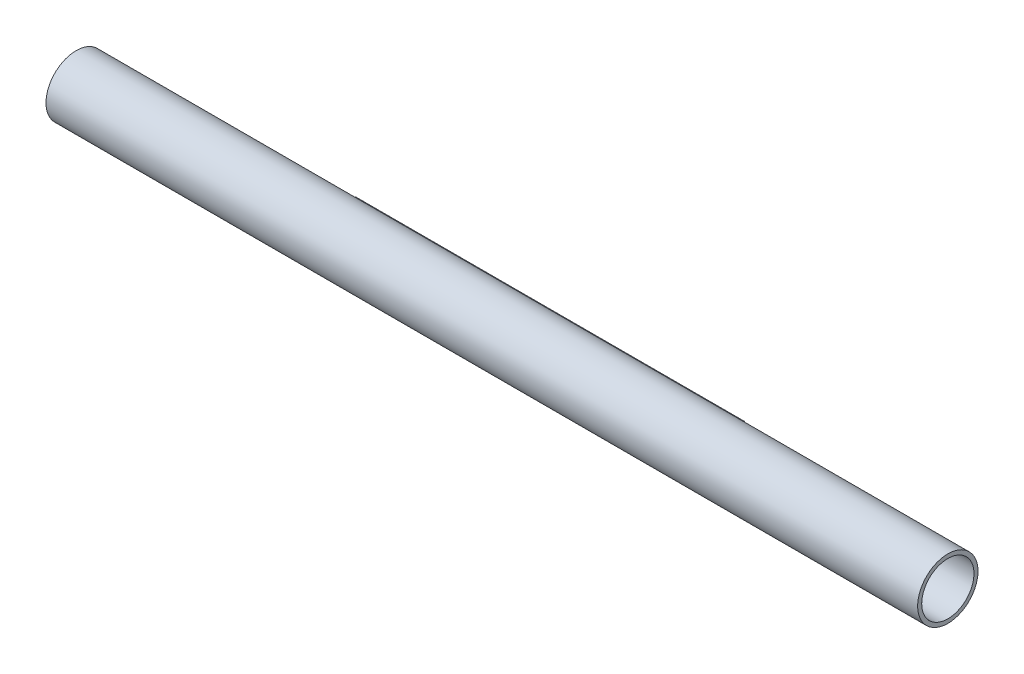
from build123d import *

# Parameters (mm, degrees)
BOSS_EXTRUDE1_DEPTH = 491.49
SKETCH2_R           = 38.1
BOSS_EXTRUDE2_DEPTH = 304.8
SKETCH3_R           = 38.1
BOSS_EXTRUDE3_DEPTH = 304.8
SKETCH4_R           = 33.02
CUT_EXTRUDE1_DEPTH  = 1102.09


with BuildPart() as part:
    # Sketch1 → Boss-Extrude1 (new body)
    with BuildSketch(Plane(origin=(0, 0, 0), x_dir=(0, 0, -1), z_dir=(1, 0, 0))):
        with BuildLine():
            Line((27.94, 6.35), (27.94, -6.35))
            Line((27.94, -6.35), (37.567106623, -6.35))
            ThreePointArc((37.567106623, -6.35), (37.966542918, -3.186160517), (38.1, 0))
            ThreePointArc((38.1, 0), (37.966542918, 3.186160517), (37.567106623, 6.35))
            Line((37.567106623, 6.35), (27.94, 6.35))
        make_face()
        with BuildLine():
            Line((37.567106623, -6.35), (27.94, -6.35))
            Line((27.94, -6.35), (27.94, 6.35))
            Line((27.94, 6.35), (37.567106623, 6.35))
            ThreePointArc((37.567106623, 6.35), (-38.1, 0), (37.567106623, -6.35))
        make_face()
        with BuildLine():
            ThreePointArc((38.1, 0), (37.966542918, -3.186160517), (37.567106623, -6.35))
            Line((37.567106623, -6.35), (48.26, -6.35))
            Line((48.26, -6.35), (48.26, 6.35))
            Line((48.26, 6.35), (37.567106623, 6.35))
            ThreePointArc((37.567106623, 6.35), (37.966542918, 3.186160517), (38.1, 0))
        make_face()
    extrude(amount=-BOSS_EXTRUDE1_DEPTH)

    # Sketch2 → Boss-Extrude2 (add)
    with BuildSketch(Plane(origin=(0, 0, 0), x_dir=(0, 0, -1), z_dir=(1, 0, 0))):
        Circle(SKETCH2_R)
    extrude(amount=BOSS_EXTRUDE2_DEPTH)

    # Sketch3 → Boss-Extrude3 (add)
    with BuildSketch(Plane.ZY.offset(491.49)):
        Circle(SKETCH3_R)
    extrude(amount=BOSS_EXTRUDE3_DEPTH)

    # Sketch4 → Cut-Extrude1 (cut, through all)
    with BuildSketch(Plane.ZY.offset(796.29)):
        Circle(SKETCH4_R)
    extrude(amount=-CUT_EXTRUDE1_DEPTH, mode=Mode.SUBTRACT)


solid = part.part
